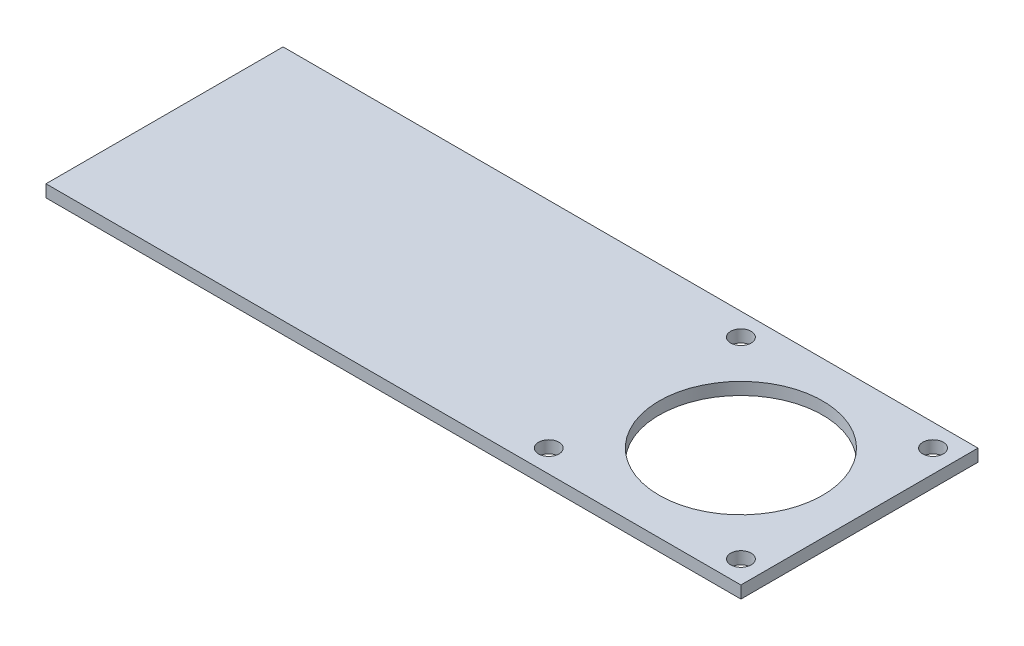
from build123d import *

# Parameters (mm, degrees)
SKETCH1_W           = 170
SKETCH1_H           = 3
BOSS_EXTRUDE1_DEPTH = 58
SKETCH2_R           = 2.5
SKETCH2_R_2         = 20
CUT_EXTRUDE1_DEPTH  = 58


with BuildPart() as part:
    # Sketch1 → Boss-Extrude1 (new body)
    with BuildSketch(Plane.XY):
        with Locations((-6.063612364, -1.5)):
            Rectangle(SKETCH1_W, SKETCH1_H)
    extrude(amount=BOSS_EXTRUDE1_DEPTH)

    # Sketch2 → Cut-Extrude1 (cut)
    with BuildSketch(Plane(origin=(0, 0, 0), x_dir=(1, 0, 0), z_dir=(0, 1, 0))):
        with Locations((73.436387636, -5.5)):
            Circle(SKETCH2_R)
        with Locations((73.436387636, -52.5)):
            Circle(SKETCH2_R)
        with Locations((26.436387636, -52.5)):
            Circle(SKETCH2_R)
        with Locations((26.436387636, -5.5)):
            Circle(SKETCH2_R)
        with Locations((49.936387636, -29)):
            Circle(SKETCH2_R_2)
    extrude(amount=-CUT_EXTRUDE1_DEPTH, mode=Mode.SUBTRACT)


solid = part.part
